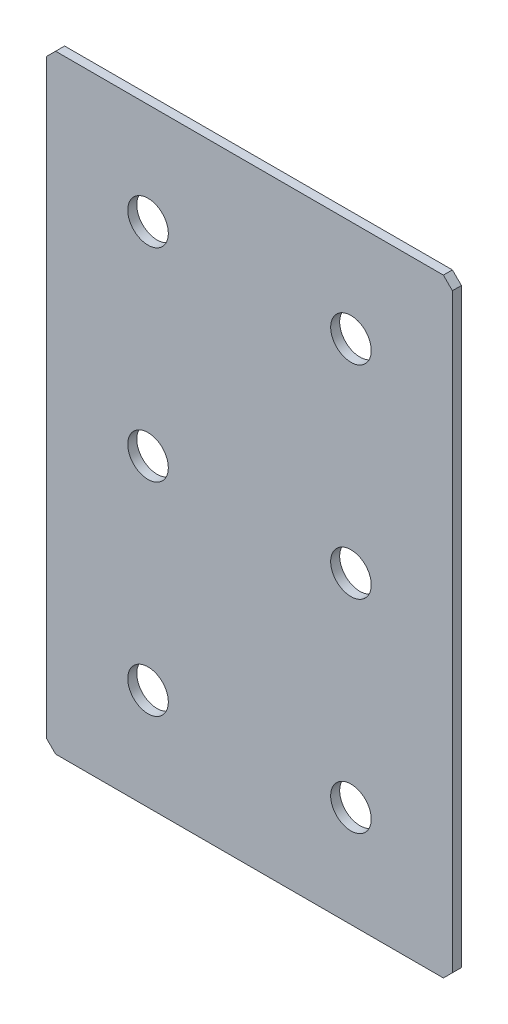
from build123d import *

# Parameters (mm, degrees)
SKETCH_1_W        = 90
SKETCH_1_H        = 135
EXTRUDE_1_DEPTH   = 2
CHAMFER_1_SIZE    = 2
HOLE_WIZARD_M81_D = 9


with BuildPart() as part:
    # Эскиз1 → Бобышка-Вытянуть1 (new body)
    with BuildSketch(Plane.XY):
        Rectangle(SKETCH_1_W, SKETCH_1_H)
    extrude(amount=EXTRUDE_1_DEPTH)

    # Фаска1
    chamfer_1_edges = [part.edges().sort_by_distance(p)[0] for p in [
        (45, -67.5, 1),
        (-45, -67.5, 1),
        (-45, 67.5, 1),
        (45, 67.5, 1),
    ]]
    chamfer(chamfer_1_edges, length=CHAMFER_1_SIZE)

    # Отверстие с зазором M81 (through all)
    with Locations(Plane.XY.offset(2)):
        with Locations((-22.5, 45), (22.5, 45), (22.5, 0), (-22.5, 0), (-22.5, -45), (22.5, -45)):
            Hole(HOLE_WIZARD_M81_D / 2)


solid = part.part
